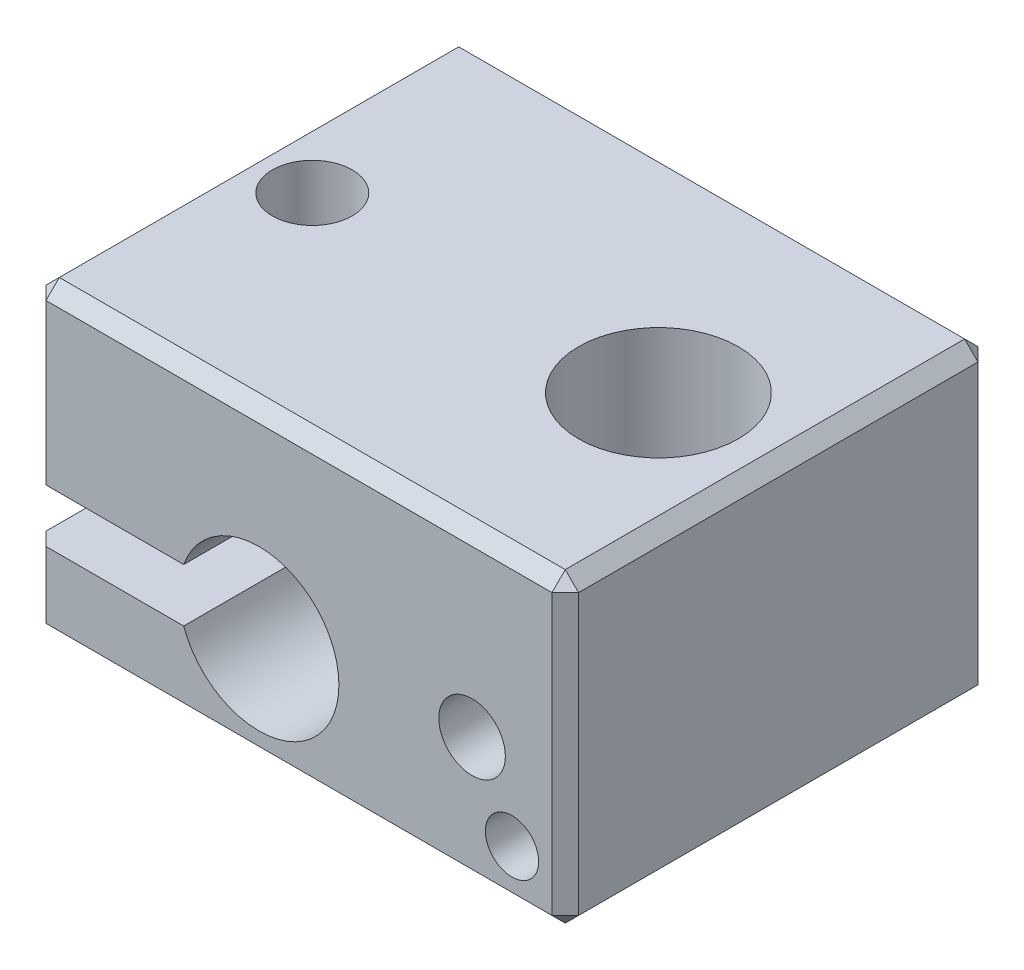
from build123d import *

# Parameters (mm, degrees)
SKETCH1_W           = 20
SKETCH1_H           = 16
SKETCH1_R           = 3
SKETCH1_R_2         = 1.5
BOSS_EXTRUDE1_DEPTH = 11.5
CUT_EXTRUDE1_DEPTH  = 17
SKETCH3_R           = 1.25
SKETCH3_R_2         = 1
CUT_EXTRUDE2_DEPTH  = 3
CHAMFER1_SIZE       = 0.5


with BuildPart() as part:
    # Sketch1 → Boss-Extrude1 (new body)
    with BuildSketch(Plane(origin=(0, 0, 0), x_dir=(1, 0, 0), z_dir=(0, 1, 0))):
        Rectangle(SKETCH1_W, SKETCH1_H)
        with Locations((5.5, 0)):
            Circle(SKETCH1_R, mode=Mode.SUBTRACT)
        with Locations((-7.5, 0)):
            Circle(SKETCH1_R_2, mode=Mode.SUBTRACT)
    extrude(amount=BOSS_EXTRUDE1_DEPTH)

    # Sketch2 → Cut-Extrude1 (cut, through all)
    with BuildSketch(Plane.XY.offset(8)):
        with BuildLine():
            Line((-10, 5), (-4.328427125, 5))
            ThreePointArc((-4.328427125, 5), (1.5, 4), (-4.328427125, 3))
            Line((-4.328427125, 3), (-10, 3))
            Line((-10, 3), (-10, 5))
        make_face()
    extrude(amount=-CUT_EXTRUDE1_DEPTH, mode=Mode.SUBTRACT)

    # Sketch3 → Cut-Extrude2 (cut)
    with BuildSketch(Plane.XY.offset(8)):
        with Locations((6.5, 4.8)):
            Circle(SKETCH3_R)
        with Locations((8, 2)):
            Circle(SKETCH3_R_2)
    extrude(amount=-CUT_EXTRUDE2_DEPTH, mode=Mode.SUBTRACT)

    # Chamfer1
    chamfer1_edges = [part.edges().sort_by_distance(p)[0] for p in [
        (10, 11.5, 0),
        (0, 11.5, -8),
        (-10, 1.5, -8),
        (-10, 1.5, 8),
        (-10, 11.5, 0),
        (0, 0, -8),
        (10, 0, 0),
        (0, 0, 8),
        (-10, 0, 0),
        (0, 11.5, 8),
        (-10, 8.25, -8),
        (10, 5.75, -8),
        (10, 5.75, 8),
        (-10, 8.25, 8),
    ]]
    chamfer(chamfer1_edges, length=CHAMFER1_SIZE)


solid = part.part
